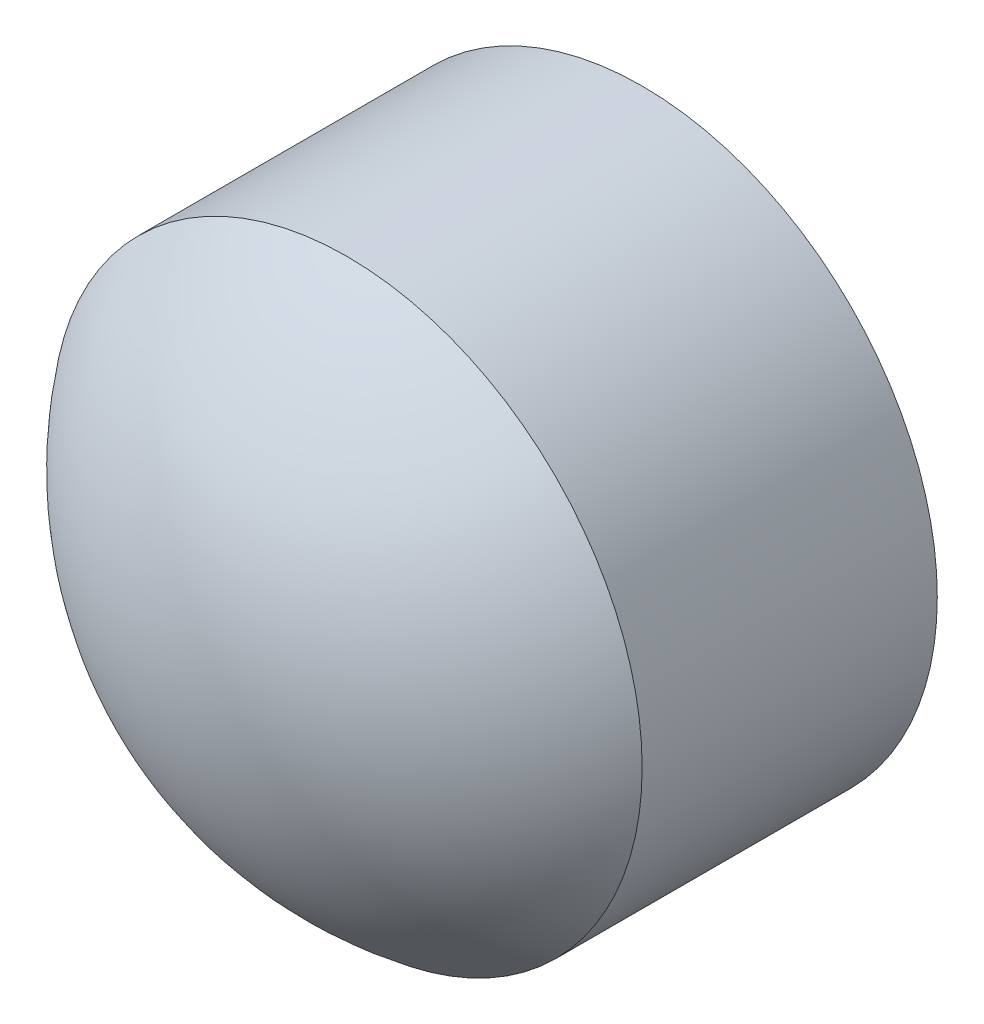
from build123d import *

# Parameters (mm, degrees)
SKETCH1_R         = 1
EXTRUDE1_DEPTH    = 1
DOME1_FACE_RADIUS = 1
DOME1_HEIGHT      = 0.5


with BuildPart() as part:
    # Sketch1 → Extrude1 (new body)
    with BuildSketch(Plane.XY):
        with Locations((0, 2.875)):
            Circle(SKETCH1_R)
    extrude(amount=EXTRUDE1_DEPTH)

    # Dome1: a dome of height H over a round flat face of radius A is a cap of a sphere of radius (A * A + H * H) / (2 * H)
    dome1_r = (DOME1_FACE_RADIUS * DOME1_FACE_RADIUS + DOME1_HEIGHT * DOME1_HEIGHT) / (2 * DOME1_HEIGHT)
    dome1_base = Plane((0, 2.875, 1), z_dir=(0, 0, 1))
    with Locations(dome1_base.offset(DOME1_HEIGHT - dome1_r)):
        dome1_ball = Sphere(dome1_r, mode=Mode.PRIVATE)
    add(split(dome1_ball, bisect_by=dome1_base, keep=Keep.TOP, mode=Mode.PRIVATE))


solid = part.part
